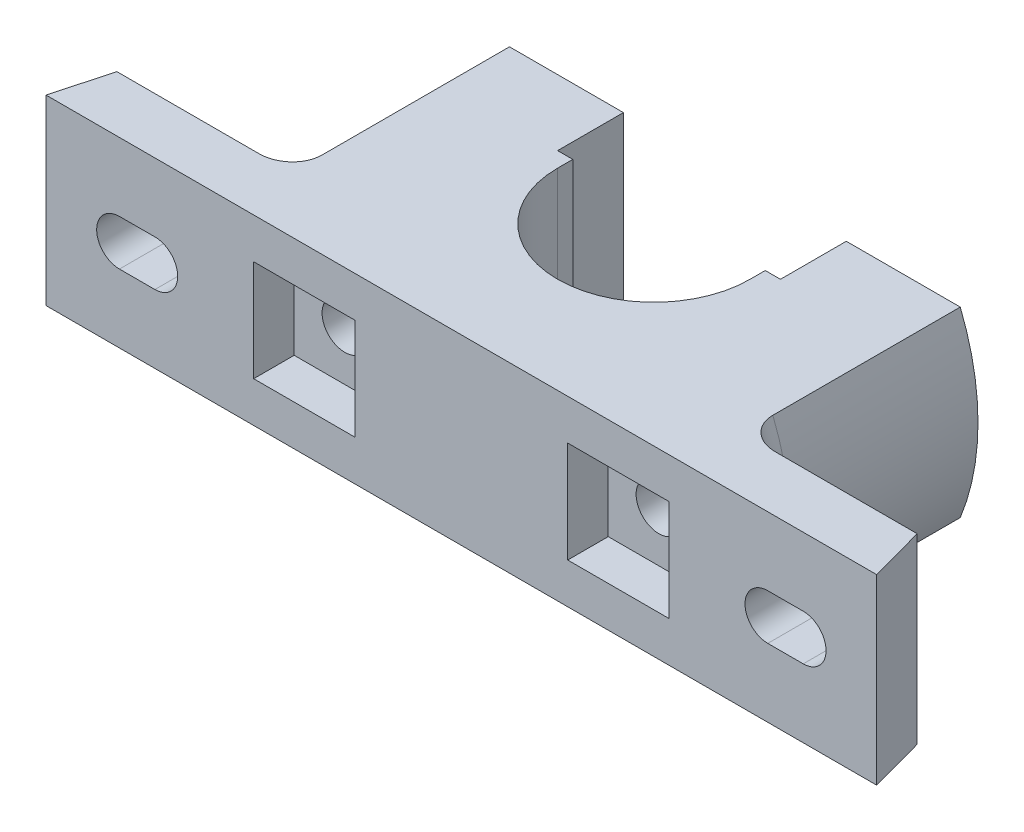
from build123d import *

# Parameters (mm, degrees)
BOSS_EXTRUDE1_DEPTH       = 18
SKETCH3_W                 = 20
SKETCH3_H                 = 20
CUT_EXTRUDE3_DEPTH        = 8
SKETCH5_R                 = 4.5
CUT_EXTRUDE4_DEPTH        = 47
CUT_EXTRUDE1_DEPTH        = 43
FILLET1_R                 = 6
CUT_EXTRUDE5_DEPTH        = 55.0000001
SKETCH8_R                 = 4.5
CUT_EXTRUDE6_DEPTH        = 55.0000001
SKETCH9_W                 = 20
SKETCH9_H                 = 20
CUT_EXTRUDE7_DEPTH        = 8
F_6_0MM_DOWEL_HOLE1_D     = 6
F_6_0MM_DOWEL_HOLE1_DEPTH = 6
F_6_0MM_DOWEL_HOLE1_TIP   = 1.802581857


with BuildPart() as part:
    # Sketch1 → Boss-Extrude1 (new body, symmetric)
    with BuildSketch(Plane(origin=(0, 0, 0), x_dir=(1, 0, 0), z_dir=(0, 1, 0))):
        with BuildLine():
            Line((-82, 0), (82, 0))
            Line((82, 0), (79, 11))
            Line((79, 11), (50, 11))
            Line((50, 11), (50, 54))
            Line((50, 54), (22, 54))
            Line((22, 54), (22, 41))
            Line((22, 41), (19, 41))
            Line((19, 41), (19, 38))
            ThreePointArc((19, 38), (0, 19), (-19, 38))
            Line((-19, 38), (-19, 41))
            Line((-19, 41), (-22, 41))
            Line((-22, 41), (-22, 54))
            Line((-22, 54), (-50, 54))
            Line((-50, 54), (-50, 11))
            Line((-50, 11), (-79, 11))
            Line((-79, 11), (-82, 0))
        make_face()
    extrude(amount=BOSS_EXTRUDE1_DEPTH, both=True)

    # Sketch3 → Cut-Extrude3 (cut)
    with BuildSketch(Plane.XY):
        with Locations((-31, 0)):
            Rectangle(SKETCH3_W, SKETCH3_H)
    extrude(amount=-CUT_EXTRUDE3_DEPTH, mode=Mode.SUBTRACT)

    # Sketch5 → Cut-Extrude4 (cut, through all)
    with BuildSketch(Plane.XY.offset(-8)):
        with Locations((-31, 0)):
            Circle(SKETCH5_R)
    extrude(amount=-CUT_EXTRUDE4_DEPTH, mode=Mode.SUBTRACT)

    # Sketch2 → Cut-Extrude1 (cut)
    with BuildSketch(Plane(origin=(0, 0, -54), x_dir=(-1, 0, 0), z_dir=(0, 0, -1))):
        with BuildLine():
            Line((50, -18), (50, 18))
            Line((50, 18), (44.497190923, 18))
            ThreePointArc((44.497190923, 18), (48, 0), (44.497190923, -18))
            Line((44.497190923, -18), (50, -18))
        make_face()
        with BuildLine():
            ThreePointArc((-44.497190923, 18), (-48, 0), (-44.497190923, -18))
            Line((-44.497190923, -18), (-50, -18))
            Line((-50, -18), (-50, 18))
            Line((-50, 18), (-44.497190923, 18))
        make_face()
    extrude(amount=-CUT_EXTRUDE1_DEPTH, mode=Mode.SUBTRACT)

    # Fillet1
    fillet1_edges = [part.edges().sort_by_distance(p)[0] for p in [
        (-48, 0, -11),
        (48, 0, -11),
    ]]
    fillet(fillet1_edges, radius=FILLET1_R)

    # Sketch6 → Cut-Extrude5 (cut, through all)
    with BuildSketch(Plane.XY):
        with BuildLine():
            Line((-60.5, -4.5), (-67.5, -4.5))
            ThreePointArc((-67.5, -4.5), (-72, 0), (-67.5, 4.5))
            Line((-67.5, 4.5), (-60.5, 4.5))
            ThreePointArc((-60.5, 4.5), (-56, 0), (-60.5, -4.5))
        make_face()
    cut_extrude5 = extrude(amount=-CUT_EXTRUDE5_DEPTH, mode=Mode.SUBTRACT)

    # Sketch8 → Cut-Extrude6 (cut, through all)
    with BuildSketch(Plane.XY):
        with Locations((31, 0)):
            Circle(SKETCH8_R)
    extrude(amount=-CUT_EXTRUDE6_DEPTH, mode=Mode.SUBTRACT)

    # Sketch9 → Cut-Extrude7 (cut)
    with BuildSketch(Plane.XY):
        with Locations((31, 0)):
            Rectangle(SKETCH9_W, SKETCH9_H)
    extrude(amount=-CUT_EXTRUDE7_DEPTH, mode=Mode.SUBTRACT)

    # Ø6.0mm Dowel Hole1
    with Locations(Plane(origin=(0, 0, -19), x_dir=(-1, 0, 0), z_dir=(0, 0, -1))):
        with Locations((0, 0)):
            Hole(F_6_0MM_DOWEL_HOLE1_D / 2, depth=F_6_0MM_DOWEL_HOLE1_DEPTH)
            with Locations((0, 0, -(F_6_0MM_DOWEL_HOLE1_DEPTH + F_6_0MM_DOWEL_HOLE1_TIP / 2))):  # 118° drill point
                Cone(0, F_6_0MM_DOWEL_HOLE1_D / 2, F_6_0MM_DOWEL_HOLE1_TIP, mode=Mode.SUBTRACT)

    # Mirror3: Cut-Extrude5 across plane
    add(cut_extrude5.mirror(Plane(origin=(0, 0, 0), x_dir=(0, 0, 1), z_dir=(1, 0, 0))), mode=Mode.SUBTRACT)


solid = part.part
